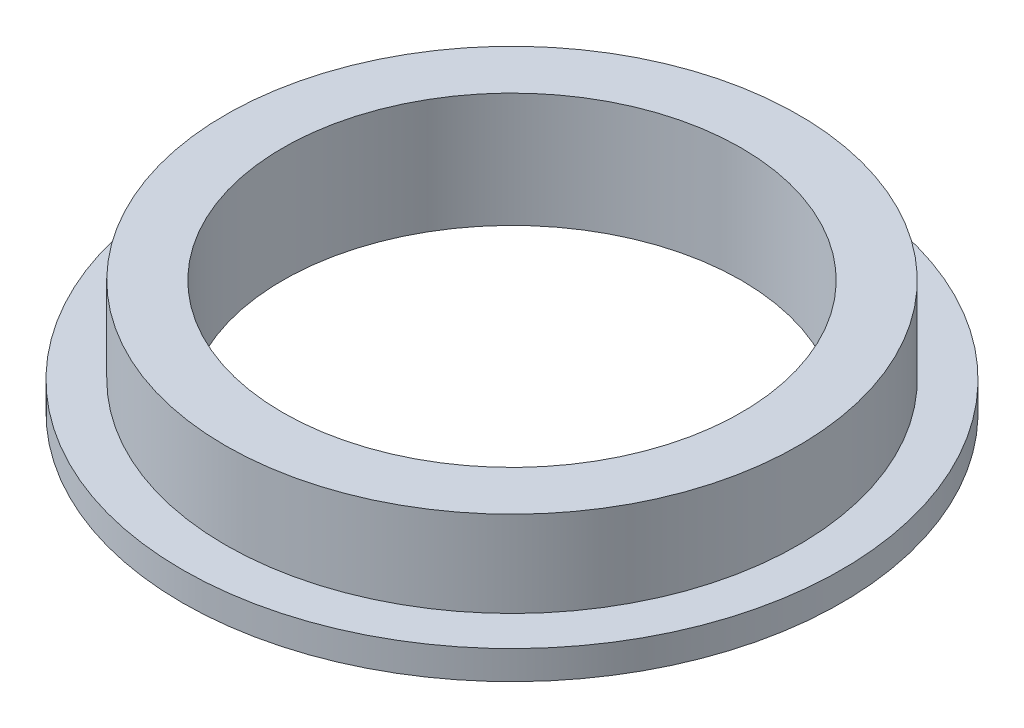
from build123d import *

# Parameters (mm, degrees)
SKETCH2_R           = 15.875
SKETCH2_R_2         = 12.7
BOSS_EXTRUDE1_DEPTH = 25.4
SKETCH3_R           = 18.25625
SKETCH3_R_2         = 15.875
BOSS_EXTRUDE2_DEPTH = 1.5875
SKETCH5_R           = 18.25625
CUT_EXTRUDE1_DEPTH  = 19.05


with BuildPart() as part:
    # Sketch2 → Boss-Extrude1 (new body)
    with BuildSketch(Plane(origin=(0, 0, 0), x_dir=(1, 0, 0), z_dir=(0, 1, 0))):
        Circle(SKETCH2_R)
        Circle(SKETCH2_R_2, mode=Mode.SUBTRACT)
    extrude(amount=BOSS_EXTRUDE1_DEPTH)

    # Sketch3 → Boss-Extrude2 (add)
    with BuildSketch(Plane(origin=(0, 0, 0), x_dir=(1, 0, 0), z_dir=(0, 1, 0))):
        Circle(SKETCH3_R)
        Circle(SKETCH3_R_2, mode=Mode.SUBTRACT)
    extrude(amount=BOSS_EXTRUDE2_DEPTH)

    # Sketch5 → Cut-Extrude1 (cut)
    with BuildSketch(Plane(origin=(0, 25.4, 0), x_dir=(1, 0, 0), z_dir=(0, 1, 0))):
        Circle(SKETCH5_R)
    extrude(amount=-CUT_EXTRUDE1_DEPTH, mode=Mode.SUBTRACT)


solid = part.part
